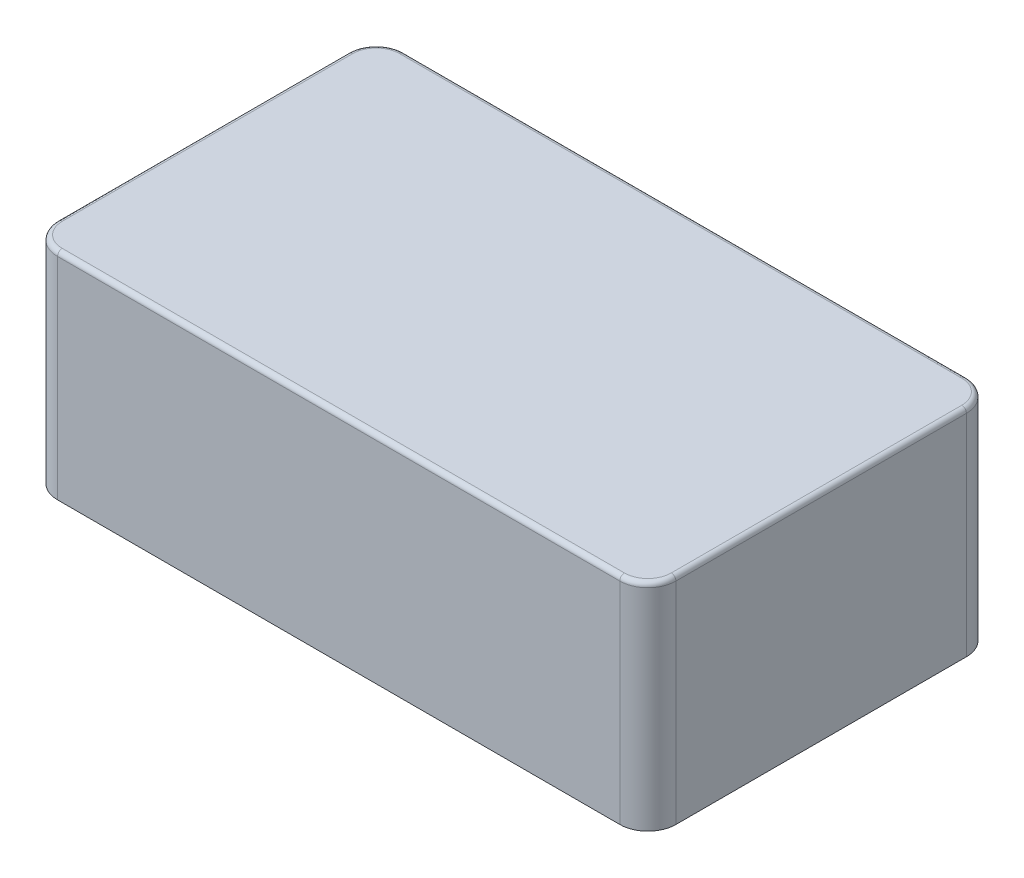
from build123d import *

# Parameters (mm, degrees)
BOSS_EXTRUDE1_DEPTH = 21
BOSS_EXTRUDE2_DEPTH = 2
FILLET1_R           = 0.5


with BuildPart() as part:
    # Sketch1 → Boss-Extrude1 (new body)
    with BuildSketch(Plane(origin=(0, 0, 0), x_dir=(1, 0, 0), z_dir=(0, 1, 0))):
        with BuildLine():
            Line((-30, 18.5), (30, 18.5))
            ThreePointArc((30, 18.5), (32.121320344, 17.621320344), (33, 15.5))
            Line((33, 15.5), (33, -15.5))
            ThreePointArc((33, -15.5), (32.121320344, -17.621320344), (30, -18.5))
            Line((30, -18.5), (-30, -18.5))
            ThreePointArc((-30, -18.5), (-32.121320344, -17.621320344), (-33, -15.5))
            Line((-33, -15.5), (-33, 15.5))
            ThreePointArc((-33, 15.5), (-32.121320344, 17.621320344), (-30, 18.5))
        make_face()
        with BuildLine():
            Line((-28, 16.5), (28, 16.5))
            ThreePointArc((28, 16.5), (30.121320344, 15.621320344), (31, 13.5))
            Line((31, 13.5), (31, -13.5))
            ThreePointArc((31, -13.5), (30.121320344, -15.621320344), (28, -16.5))
            Line((28, -16.5), (-28, -16.5))
            ThreePointArc((-28, -16.5), (-30.121320344, -15.621320344), (-31, -13.5))
            Line((-31, -13.5), (-31, 13.5))
            ThreePointArc((-31, 13.5), (-30.121320344, 15.621320344), (-28, 16.5))
        make_face(mode=Mode.SUBTRACT)
    extrude(amount=BOSS_EXTRUDE1_DEPTH)

    # Sketch2 → Boss-Extrude2 (add)
    with BuildSketch(Plane(origin=(0, 21, 0), x_dir=(1, 0, 0), z_dir=(0, 1, 0))):
        with BuildLine():
            Line((-30, 18.5), (30, 18.5))
            ThreePointArc((30, 18.5), (32.121320344, 17.621320344), (33, 15.5))
            Line((33, 15.5), (33, -15.5))
            ThreePointArc((33, -15.5), (32.121320344, -17.621320344), (30, -18.5))
            Line((30, -18.5), (-30, -18.5))
            ThreePointArc((-30, -18.5), (-32.121320344, -17.621320344), (-33, -15.5))
            Line((-33, -15.5), (-33, 15.5))
            ThreePointArc((-33, 15.5), (-32.121320344, 17.621320344), (-30, 18.5))
        make_face()
    extrude(amount=BOSS_EXTRUDE2_DEPTH)

    # Fillet1
    fillet1_edges = [part.edges().sort_by_distance(p)[0] for p in [
        (-32.121320344, 23, 17.621320344),
        (0, 23, 18.5),
        (32.121320344, 23, 17.621320344),
        (33, 23, 0),
        (32.121320344, 23, -17.621320344),
        (0, 23, -18.5),
        (-32.121320344, 23, -17.621320344),
        (-33, 23, 0),
    ]]
    fillet(fillet1_edges, radius=FILLET1_R)


solid = part.part
